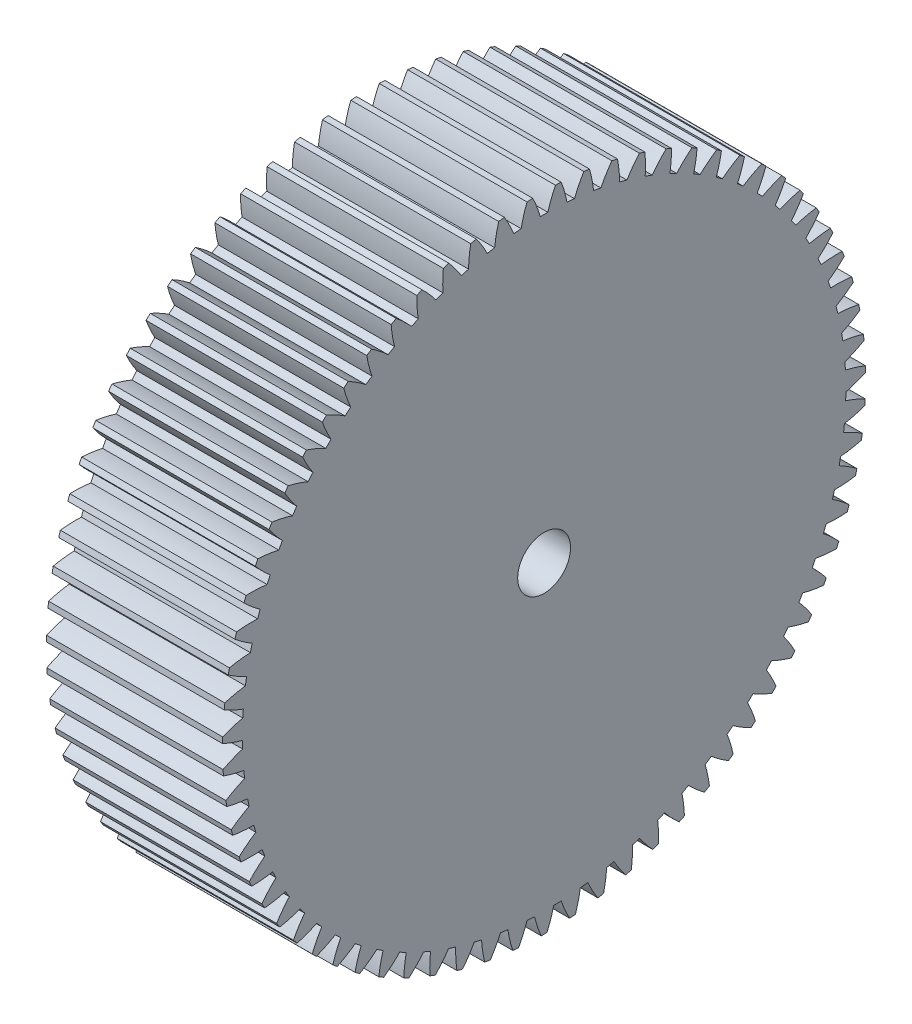
from build123d import *

# Parameters (mm, degrees)
BASPROSKE_W     = 10
BASPROSKE_H     = 18.25
TOOTHCUT_DEPTH  = 28.678963131
TEETHCUTS_COUNT = 71
TEETHCUTS_ANGLE = 354.929577465
BORSKE_R        = 1.5
BORE_DEPTH      = 50.0000508


with BuildPart() as part:
    # BasProSke → Base-Revolve (revolve)
    with BuildSketch(Plane(origin=(0, 0, 0), x_dir=(1, 0, 0), z_dir=(0, 1, 0)), mode=Mode.PRIVATE) as base_revolve_sk:
        with Locations((5, 9.125)):
            Rectangle(BASPROSKE_W, BASPROSKE_H)
    revolve(base_revolve_sk.sketch.rotate(Axis((-10, 0, 0), (1, 0, 0)), 180), axis=Axis((-10, 0, 0), (1, 0, 0)))

    # TooCutSke → ToothCut (cut, through all)
    with BuildSketch(Plane(origin=(0, 0, 0), x_dir=(0, 0, -1), z_dir=(1, 0, 0))):
        with BuildLine():
            ThreePointArc((0.211970544, 17.122688004), (0, 17.124), (-0.211970544, 17.122688004))
            ThreePointArc((-0.211970544, 17.122688004), (-0.409357828, 17.702744085), (-0.656021561, 18.26362179))
            ThreePointArc((-0.656021561, 18.26362179), (0, 18.2754), (0.656021561, 18.26362179))
            ThreePointArc((0.656021561, 18.26362179), (0.409357828, 17.702744085), (0.211970544, 17.122688004))
        make_face()
    toothcut = extrude(amount=TOOTHCUT_DEPTH, mode=Mode.SUBTRACT)

    # TeethCuts: ToothCut ×71 about axis
    teethcuts_axis = Axis((-10, 0, 0), (1, 0, 0))
    for i in range(1, TEETHCUTS_COUNT):
        add(toothcut.rotate(teethcuts_axis, i * TEETHCUTS_ANGLE / (TEETHCUTS_COUNT - 1)), mode=Mode.SUBTRACT)

    # BorSke → Bore (cut, symmetric)
    with BuildSketch(Plane(origin=(0, 0, 0), x_dir=(0, 0, -1), z_dir=(1, 0, 0))):
        with Locations(Location((0, 0, 0), (0, 0, 180))):
            Circle(BORSKE_R)
    extrude(amount=BORE_DEPTH, both=True, mode=Mode.SUBTRACT)


solid = part.part
